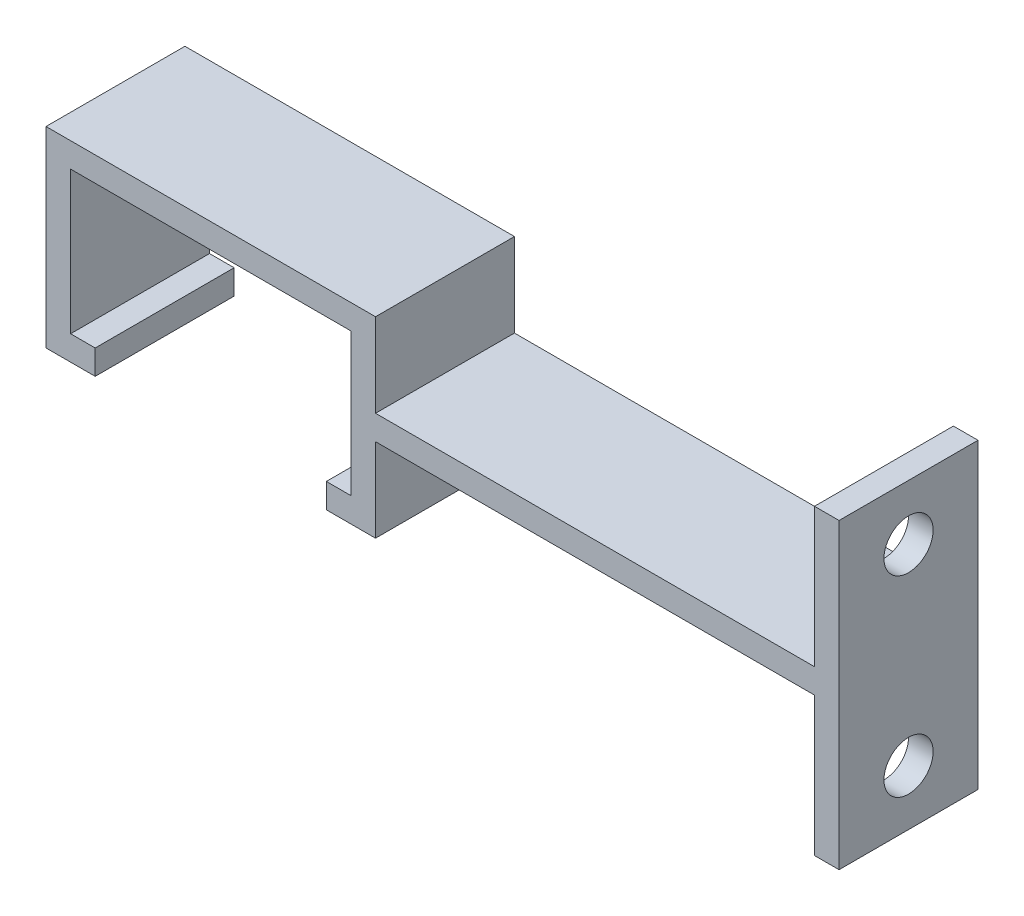
from build123d import *

# Parameters (mm, degrees)
BOSS_EXTRU_1_DEPTH      = 11.3
ESQUISSE2_W             = 8.8
ESQUISSE2_H             = 11.3
BOSS_EXTRU_2_DEPTH      = 1
ESQUISSE8_W             = 11.3
ESQUISSE8_H             = 1
BOSS_EXTRU_5_DEPTH      = 10
ESQUISSE9_W             = 2
ESQUISSE9_H             = 11.3
BOSS_EXTRU_6_DEPTH      = 7.8
ESQUISSE10_W            = 11.3
ESQUISSE10_H            = 2
BOSS_EXTRU_7_DEPTH      = 36.7
ESQUISSE11_W            = 2
ESQUISSE11_H            = 11.3
BOSS_EXTRU_8_DEPTH      = 11.3
ESQUISSE12_W            = 2
ESQUISSE12_H            = 11.3
BOSS_EXTRU_9_DEPTH      = 11.3
BOSS_EXTRU_10_DEPTH     = 11.3
ESQUISSE14_W            = 1
ESQUISSE14_H            = 11.3
BOSS_EXTRU_11_DEPTH     = 5.8
ESQUISSE16_W            = 11.3
ESQUISSE16_H            = 6.8
ENL_V_MAT_EXTRU_1_DEPTH = 1
ESQUISSE19_R            = 2
ENL_V_MAT_EXTRU_3_DEPTH = 10
ESQUISSE22_W            = 4
ESQUISSE22_H            = 1
BOSS_EXTRU_12_DEPTH     = 11.3


with BuildPart() as part:
    # Esquisse1 → Boss.-Extru.1 (new body)
    with BuildSketch(Plane.XY):
        Polygon((-21.8, 1), (-21.8, 0), (-24.8, 0), (-24.8, 13.6), (0, 13.6), (0, 0), (-3, 0), (-3, 1), (-1, 1), (-1, 12.6), (-23.8, 12.6), (-23.8, 1), align=None)
    extrude(amount=BOSS_EXTRU_1_DEPTH)

    # Esquisse2 → Boss.-Extru.2 (add)
    with BuildSketch(Plane(origin=(0, 13.6, 0), x_dir=(1, 0, 0), z_dir=(0, 1, 0))):
        with Locations((-12.4, -5.65)):
            Rectangle(ESQUISSE2_W, ESQUISSE2_H)
    extrude(amount=BOSS_EXTRU_2_DEPTH)

    # Esquisse8 → Boss.-Extru.5 (add)
    with BuildSketch(Plane(origin=(-8, 0, 0), x_dir=(0, 0, -1), z_dir=(1, 0, 0))):
        with Locations((-5.65, 14.1)):
            Rectangle(ESQUISSE8_W, ESQUISSE8_H)
    extrude(amount=BOSS_EXTRU_5_DEPTH)

    # Esquisse9 → Boss.-Extru.6 (add)
    with BuildSketch(Plane.XZ.offset(-13.6)):
        with Locations((1, 5.65)):
            Rectangle(ESQUISSE9_W, ESQUISSE9_H)
    extrude(amount=BOSS_EXTRU_6_DEPTH)

    # Esquisse10 → Boss.-Extru.7 (add)
    with BuildSketch(Plane(origin=(2, 0, 0), x_dir=(0, 0, -1), z_dir=(1, 0, 0))):
        with Locations((-5.65, 6.8)):
            Rectangle(ESQUISSE10_W, ESQUISSE10_H)
    extrude(amount=BOSS_EXTRU_7_DEPTH)

    # Esquisse11 → Boss.-Extru.8 (add)
    with BuildSketch(Plane.XZ.offset(-5.8)):
        with Locations((37.7, 5.65)):
            Rectangle(ESQUISSE11_W, ESQUISSE11_H)
    extrude(amount=BOSS_EXTRU_8_DEPTH)

    # Esquisse12 → Boss.-Extru.9 (add)
    with BuildSketch(Plane(origin=(0, 7.8, 0), x_dir=(1, 0, 0), z_dir=(0, 1, 0))):
        with Locations((37.7, -5.65)):
            Rectangle(ESQUISSE12_W, ESQUISSE12_H)
    extrude(amount=BOSS_EXTRU_9_DEPTH)

    # Esquisse13 → Boss.-Extru.10 (add)
    with BuildSketch(Plane.XY.offset(11.3)):
        Polygon((-16.8, 14.6), (-25.8, 14.6), (-25.8, 0), (-24.8, 0), (-24.8, 13.6), (-16.8, 13.6), align=None)
    extrude(amount=-BOSS_EXTRU_10_DEPTH)

    # Esquisse14 → Boss.-Extru.11 (add)
    with BuildSketch(Plane.XZ.offset(-5.8)):
        with Locations((0.5, 5.65)):
            Rectangle(ESQUISSE14_W, ESQUISSE14_H)
    extrude(amount=BOSS_EXTRU_11_DEPTH)

    # Esquisse16 → Enlèv. mat.-Extru.1 (cut)
    with BuildSketch(Plane(origin=(2, 0, 0), x_dir=(0, 0, -1), z_dir=(1, 0, 0))):
        with Locations((-5.65, 11.2)):
            Rectangle(ESQUISSE16_W, ESQUISSE16_H)
    extrude(amount=-ENL_V_MAT_EXTRU_1_DEPTH, mode=Mode.SUBTRACT)

    # Esquisse19 → Enlèv. mat.-Extru.3 (cut)
    with BuildSketch(Plane(origin=(38.7, 0, 0), x_dir=(0, 0, -1), z_dir=(1, 0, 0))):
        with Locations((-5.65, 14.6)):
            Circle(ESQUISSE19_R)
        with Locations((-5.65, -1)):
            Circle(ESQUISSE19_R)
    extrude(amount=-ENL_V_MAT_EXTRU_3_DEPTH, mode=Mode.SUBTRACT)

    # Esquisse22 → Boss.-Extru.12 (add)
    with BuildSketch(Plane.XY.offset(11.3)):
        with Locations((-23.8, -0.5)):
            Rectangle(ESQUISSE22_W, ESQUISSE22_H)
        with Locations((-1, -0.5)):
            Rectangle(ESQUISSE22_W, ESQUISSE22_H)
    extrude(amount=-BOSS_EXTRU_12_DEPTH)


solid = part.part
